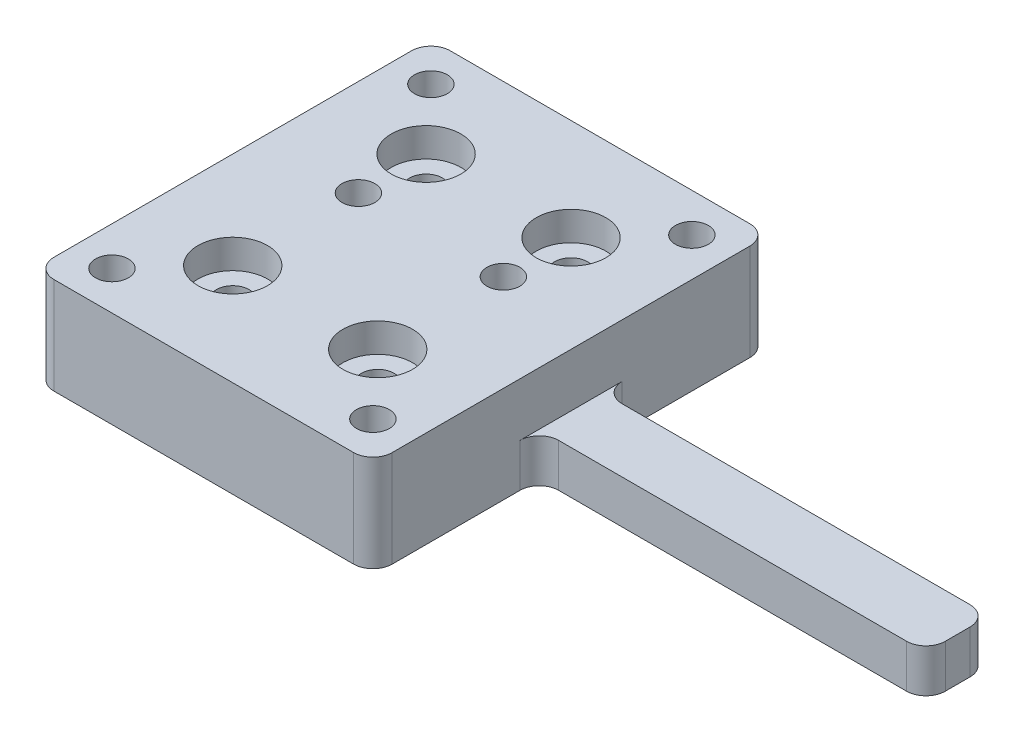
from build123d import *

# Parameters (mm, degrees)
SKETCH_1_W          = 35
SKETCH_1_H          = 41
SKETCH_1_R          = 1.7
EXTRUDE_1_DEPTH     = 10
SKETCH_2_R          = 3.6
CUT_EXTRUDE_1_DEPTH = 3
SKETCH_3_R          = 3.4
CUT_EXTRUDE_2_DEPTH = 5
SKETCH_4_R          = 1.7
CUT_EXTRUDE_3_DEPTH = 11
FILLET_1_R          = 2
SKETCH_5_W          = 6.562454648
SKETCH_5_H          = 4.478703739
EXTRUDE_2_DEPTH     = 40
FILLET_2_R          = 2


with BuildPart() as part:
    # 草图1 → 凸台-拉伸1 (new body)
    with BuildSketch(Plane(origin=(0, 0, 0), x_dir=(1, 0, 0), z_dir=(0, 1, 0))):
        with Locations((-19.214285714, 4.857142857)):
            Rectangle(SKETCH_1_W, SKETCH_1_H)
        with Locations((-26.714285714, 14.857142857)):
            Circle(SKETCH_1_R, mode=Mode.SUBTRACT)
        with Locations((-11.714285714, 14.857142857)):
            Circle(SKETCH_1_R, mode=Mode.SUBTRACT)
        with Locations((-11.714285714, -5.142857143)):
            Circle(SKETCH_1_R, mode=Mode.SUBTRACT)
        with Locations((-26.714285714, -5.142857143)):
            Circle(SKETCH_1_R, mode=Mode.SUBTRACT)
        with Locations((-11.714285714, 7.857142857)):
            Circle(SKETCH_1_R, mode=Mode.SUBTRACT)
        with Locations((-26.714285714, 7.857142857)):
            Circle(SKETCH_1_R, mode=Mode.SUBTRACT)
    extrude(amount=EXTRUDE_1_DEPTH)

    # 草图2 → 切除-拉伸1 (cut)
    with BuildSketch(Plane(origin=(0, 10, 0), x_dir=(1, 0, 0), z_dir=(0, 1, 0))):
        with Locations((-26.714285714, -5.142857143)):
            Circle(SKETCH_2_R)
        with Locations((-11.714285714, -5.142857143)):
            Circle(SKETCH_2_R)
        with Locations((-11.714285714, 14.857142857)):
            Circle(SKETCH_2_R)
        with Locations((-26.714285714, 14.857142857)):
            Circle(SKETCH_2_R)
    extrude(amount=-CUT_EXTRUDE_1_DEPTH, mode=Mode.SUBTRACT)

    # 草图3 → 切除-拉伸2 (cut)
    with BuildSketch(Plane.XZ):
        with Locations((-11.714285714, -7.857142857)):
            Circle(SKETCH_3_R)
        with Locations((-26.714285714, -7.857142857)):
            Circle(SKETCH_3_R)
    extrude(amount=-CUT_EXTRUDE_2_DEPTH, mode=Mode.SUBTRACT)

    # 草图4 → 切除-拉伸3 (cut, through all)
    with BuildSketch(Plane(origin=(0, 10, 0), x_dir=(1, 0, 0), z_dir=(0, 1, 0))):
        with Locations((-32.714285714, 21.357142857)):
            Circle(SKETCH_4_R)
        with Locations((-5.714285714, 21.357142857)):
            Circle(SKETCH_4_R)
        with Locations((-5.714285714, -11.642857143)):
            Circle(SKETCH_4_R)
        with Locations((-32.714285714, -11.642857143)):
            Circle(SKETCH_4_R)
    extrude(amount=-CUT_EXTRUDE_3_DEPTH, mode=Mode.SUBTRACT)

    # 圆角1
    fillet_1_edges = [part.edges().sort_by_distance(p)[0] for p in [
        (-36.714285714, 5, -25.357142857),
        (-1.714285714, 5, -25.357142857),
        (-1.714285714, 5, 15.642857143),
        (-36.714285714, 5, 15.642857143),
    ]]
    fillet(fillet_1_edges, radius=FILLET_1_R)

    # 草图5 → 凸台-拉伸2 (add)
    with BuildSketch(Plane(origin=(-1.714285714, 0, 0), x_dir=(0, 0, -1), z_dir=(1, 0, 0))):
        with Locations((4.857142857, 2.23935187)):
            Rectangle(SKETCH_5_W, SKETCH_5_H)
    extrude(amount=EXTRUDE_2_DEPTH)

    # 圆角2
    fillet_2_edges = [part.edges().sort_by_distance(p)[0] for p in [
        (-1.714285714, 2.239351869, -8.138370181),
        (-1.714285714, 2.239351869, -1.575915533),
        (38.285714286, 2.239351869, -8.138370181),
        (38.285714286, 2.239351869, -1.575915533),
    ]]
    fillet(fillet_2_edges, radius=FILLET_2_R)


solid = part.part
